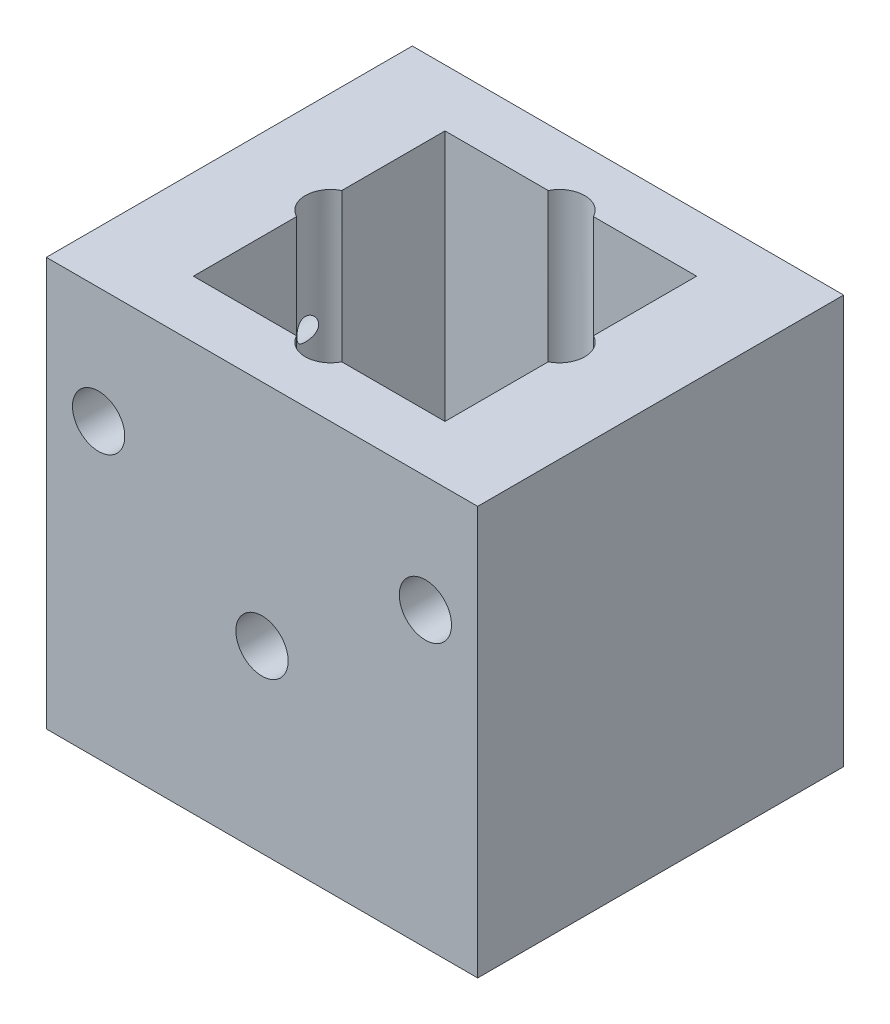
from build123d import *

# Parameters (mm, degrees)
SKETCH_1_W          = 15.4
SKETCH_1_H          = 22.4
EXTRUDE_2_DEPTH     = 3
SKETCH_1_4_W        = 15.4
SKETCH_1_4_H        = 3.5
EXTRUDE_3_DEPTH     = 10
EXTRUDE_3_2_DEPTH   = 10
SKETCH_1_5_W        = 26.4
SKETCH_1_5_H        = 22.4
SKETCH_1_5_W_2      = 15.4
SKETCH_1_5_H_2      = 15.4
EXTRUDE_4_DEPTH     = 25
SKETCH_3_R          = 1.6
CUT_EXTRUDE_2_DEPTH = 42.807654801
SKETCH_9_R          = 1.3
SKETCH_9_R_2        = 3
SKETCH_9_R_3        = 1.55
CUT_EXTRUDE_6_DEPTH = 31.408551429
SKETCH_10_R         = 3
CUT_EXTRUDE_7_DEPTH = 2


with BuildPart() as part:
    # 草图1 → 凸台-拉伸2 (new body)
    with BuildSketch(Plane(origin=(0, 0, 0), x_dir=(1, 0, 0), z_dir=(0, 1, 0))):
        Rectangle(SKETCH_1_W, SKETCH_1_H)
    extrude(amount=EXTRUDE_2_DEPTH)



with BuildPart() as body_2:
    # 草图1<4> → 凸台-拉伸3 (new body)
    with BuildSketch(Plane(origin=(0, 0, 0), x_dir=(1, 0, 0), z_dir=(0, 1, 0))):
        with Locations((0, 9.45)):
            Rectangle(SKETCH_1_4_W, SKETCH_1_4_H)
    extrude(amount=EXTRUDE_3_DEPTH)


with BuildPart() as body_3:
    # 草图1<4> → Extrude 3 2 (new body)
    with BuildSketch(Plane(origin=(0, 0, 0), x_dir=(1, 0, 0), z_dir=(0, 1, 0))):
        with Locations((0, -9.45)):
            Rectangle(SKETCH_1_4_W, SKETCH_1_4_H)
    extrude(amount=EXTRUDE_3_2_DEPTH)


with BuildPart() as part_1:
    add(part.part)

    add(body_2.part)  # 凸台-拉伸4 merges body 2

    add(body_3.part)  # 凸台-拉伸4 merges body 3
    # 草图1<5> → 凸台-拉伸4 (add)
    with BuildSketch(Plane(origin=(0, 0, 0), x_dir=(1, 0, 0), z_dir=(0, 1, 0))):
        Rectangle(SKETCH_1_5_W, SKETCH_1_5_H)
        Rectangle(SKETCH_1_5_W_2, SKETCH_1_5_H_2, mode=Mode.SUBTRACT)
    extrude(amount=EXTRUDE_4_DEPTH)

    # 草图3 → 切除-拉伸2 (cut, through all)
    with BuildSketch(Plane(origin=(0, 0, -19.6), x_dir=(-1, 0, 0), z_dir=(0, 0, -1))):
        with Locations((10, 17.91)):
            Circle(SKETCH_3_R)
        with Locations((0, 11)):
            Circle(SKETCH_3_R)
        with Locations((-10, 17.91)):
            Circle(SKETCH_3_R)
    extrude(amount=-CUT_EXTRUDE_2_DEPTH, mode=Mode.SUBTRACT)

    # 草图9 → 切除-拉伸6 (cut, through all)
    with BuildSketch(Plane.XZ):
        with Locations((-4.949747468, -4.949747468)):
            Circle(SKETCH_9_R)
        with Locations((4.949747468, -4.949747468)):
            Circle(SKETCH_9_R)
        with Locations((4.949747468, 4.949747468)):
            Circle(SKETCH_9_R)
        with Locations((-4.949747468, 4.949747468)):
            Circle(SKETCH_9_R)
        Circle(SKETCH_9_R_2)
        with Locations((7, 0)):
            Circle(SKETCH_9_R_3)
        with Locations((0, 7)):
            Circle(SKETCH_9_R_3)
        with Locations((0, -7)):
            Circle(SKETCH_9_R_3)
        with Locations((-7, 0)):
            Circle(SKETCH_9_R_3)
    extrude(amount=-CUT_EXTRUDE_6_DEPTH, mode=Mode.SUBTRACT)

    # 草图10 → 切除-拉伸7 (cut)
    with BuildSketch(Plane(origin=(0, 0, -11.2), x_dir=(-1, 0, 0), z_dir=(0, 0, -1))):
        with Locations((10, 17.91)):
            Circle(SKETCH_10_R)
        with Locations((0, 11)):
            Circle(SKETCH_10_R)
        with Locations((-10, 17.91)):
            Circle(SKETCH_10_R)
    extrude(amount=-CUT_EXTRUDE_7_DEPTH, mode=Mode.SUBTRACT)


solid = part_1.part
